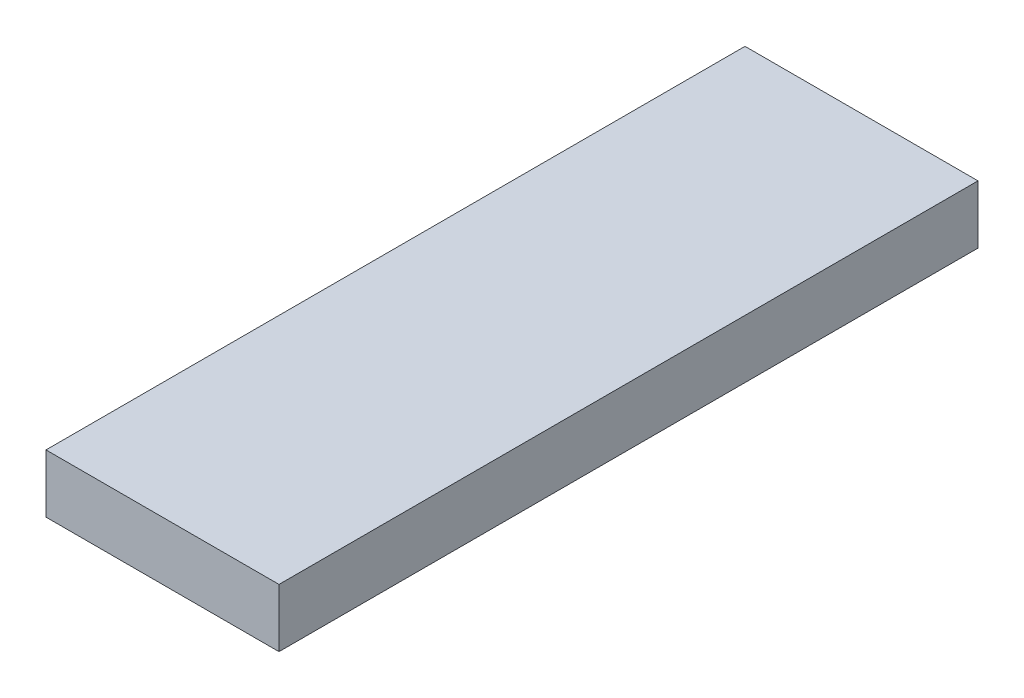
from build123d import *

# Parameters (mm, degrees)
SKETCH1_W  = 20
SKETCH1_H  = 5
LINK_DEPTH = 30


with BuildPart() as part:
    # Sketch1 → Link (new body, symmetric)
    with BuildSketch(Plane.XY):
        Rectangle(SKETCH1_W, SKETCH1_H)
    extrude(amount=LINK_DEPTH, both=True)


solid = part.part
